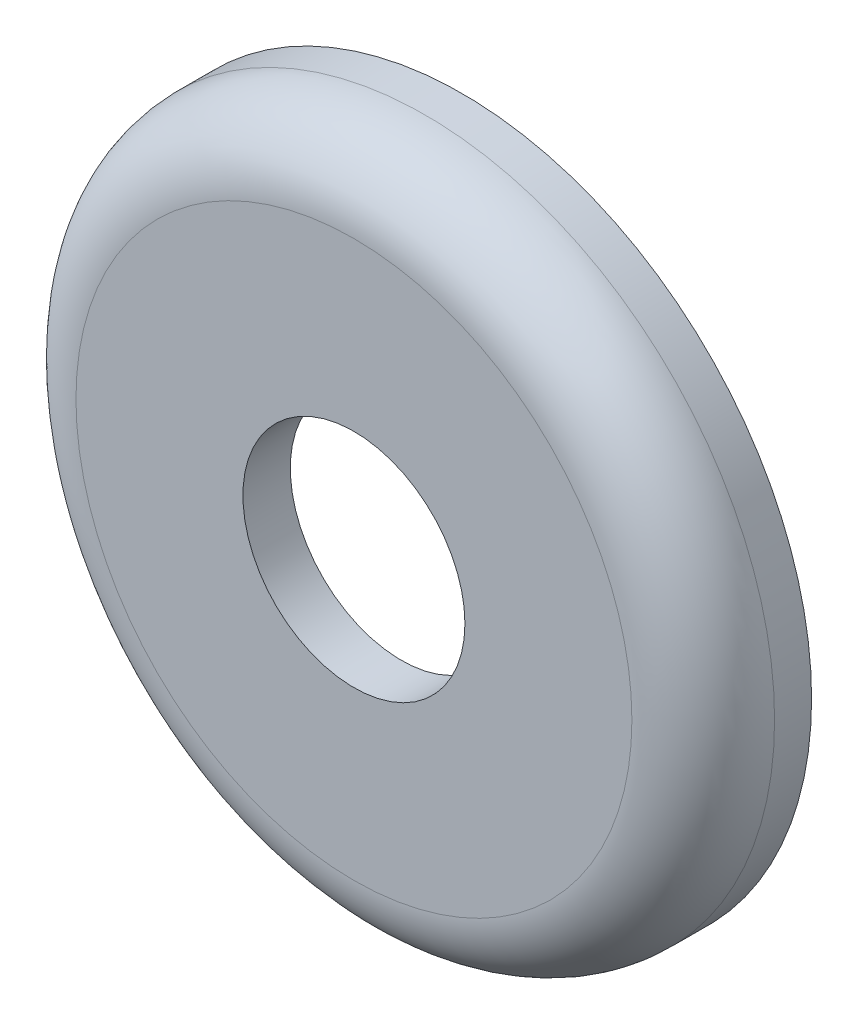
from build123d import *


with BuildPart() as part:
    # Sketch1 → Revolve1 (revolve)
    with BuildSketch(Plane(origin=(0, 0, 0), x_dir=(1, 0, 0), z_dir=(0, 1, 0))):
        with BuildLine():
            ThreePointArc((12.5603, 2.032), (12.812582596, 2.122503889), (12.949803492, 2.352738309))
            Line((12.949803492, 2.352738309), (13.3985, 4.6482))
            Line((13.3985, 4.6482), (14.986, 4.6482))
            Line((14.986, 4.6482), (14.986, 3.0607))
            ThreePointArc((14.986, 3.0607), (14.089541725, 0.896458275), (11.9253, 0))
            Line((11.9253, 0), (4.7625, 0))
            Line((4.7625, 0), (4.7625, 2.032))
            Line((4.7625, 2.032), (12.5603, 2.032))
        make_face()
    revolve(axis=Axis((0, 0, 0), (0, 0, -1)))


solid = part.part
